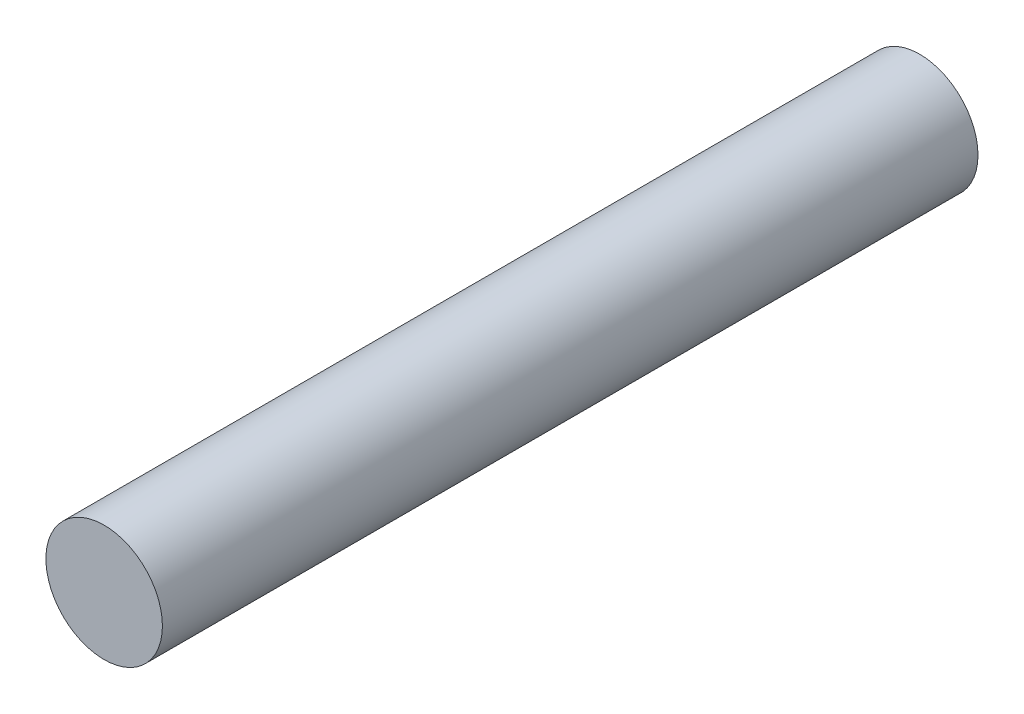
from build123d import *

# Parameters (mm, degrees)
SKETCH1_R           = 2
BOSS_EXTRUDE1_DEPTH = 14


with BuildPart() as part:
    # Sketch1 → Boss-Extrude1 (new body, symmetric)
    with BuildSketch(Plane.XY):
        Circle(SKETCH1_R)
    extrude(amount=BOSS_EXTRUDE1_DEPTH, both=True)


solid = part.part
